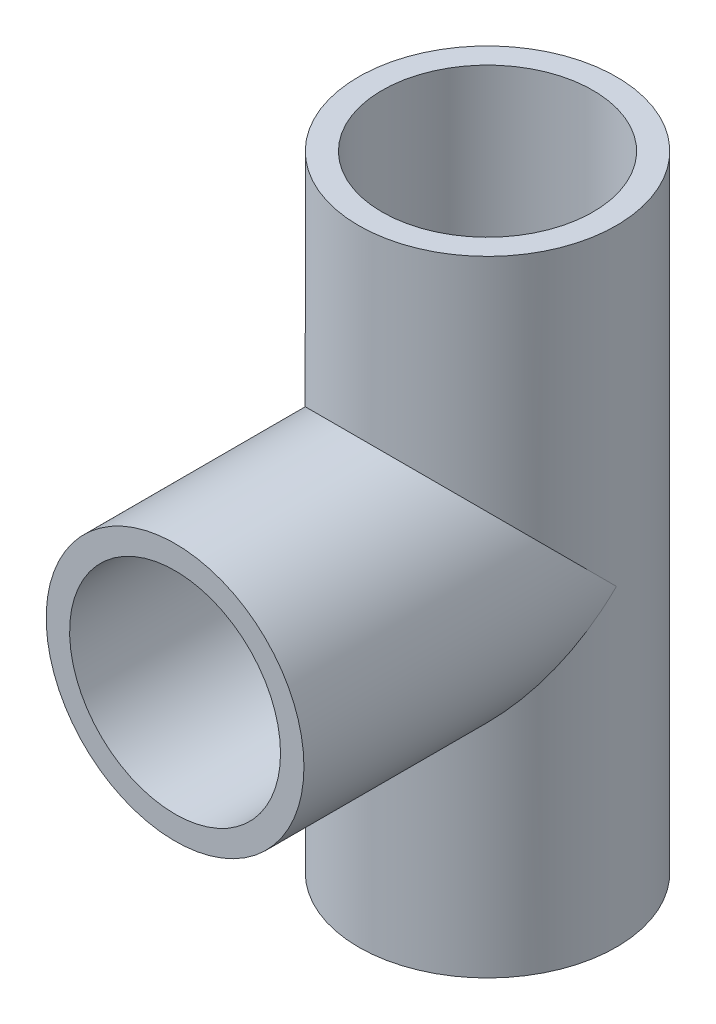
from build123d import *

# Parameters (mm, degrees)
SKETCH1_R           = 16.5
SKETCH1_R_2         = 13.5
SKETCH4_R           = 16.5
SKETCH4_R_2         = 13.5
BOSS_EXTRUDE2_DEPTH = 40


with BuildPart() as part:
    # Sweep2: sweep along a path in Sketch3
    with BuildLine(Plane.XY) as sweep2_path:
        Line((0, 0), (0, 80))
    # Sketch1 → Sweep2 (sweep)
    with BuildSketch(Plane(origin=(0, 0, 0), x_dir=(1, 0, 0), z_dir=(0, 1, 0))):
        Circle(SKETCH1_R)
        Circle(SKETCH1_R_2, mode=Mode.SUBTRACT)
    sweep(path=sweep2_path.line)

    # Sketch4 → Boss-Extrude2 (add)
    with BuildSketch(Plane.XY):
        with Locations((0, 40)):
            Circle(SKETCH4_R)
        with Locations((0, 40)):
            Circle(SKETCH4_R_2, mode=Mode.SUBTRACT)
    extrude(amount=BOSS_EXTRUDE2_DEPTH)


solid = part.part
